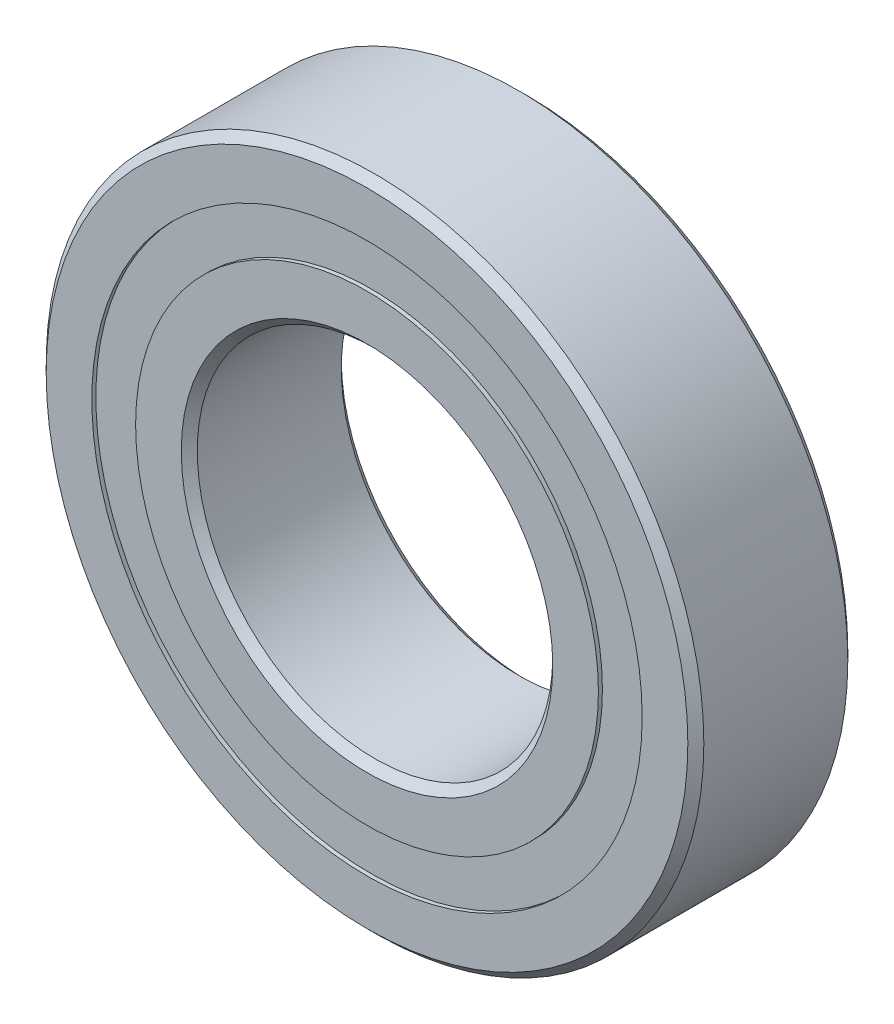
from build123d import *

# Parameters (mm, degrees)
CIRPATTERN1_COUNT = 12
SKETCH5_W         = 1.926640381
SKETCH5_H         = 2.461538462


with BuildPart() as part:
    # Sketch1 → Revolve1 (revolve)
    with BuildSketch(Plane(origin=(0, 0, 0), x_dir=(0, 0, -1), z_dir=(1, 0, 0))):
        with BuildLine():
            Line((4.05, 18.5), (-4.05, 18.5))
            Line((-4.05, 18.5), (-4.5, 18.05))
            Line((-4.5, 18.05), (-4.5, 15.480769231))
            Line((-4.5, 15.480769231), (-2, 15.480769231))
            ThreePointArc((-2, 15.480769231), (0, 16.598359619), (2, 15.480769231))
            Line((2, 15.480769231), (4.5, 15.480769231))
            Line((4.5, 15.480769231), (4.5, 18.05))
            Line((4.5, 18.05), (4.05, 18.5))
        make_face()
    revolve(axis=Axis((0, 0, 4.5), (0, 0, -1)))


with BuildPart() as body_2:
    # Sketch3 → Revolve3 (revolve)
    with BuildSketch(Plane(origin=(0, 0, 0), x_dir=(0, 0, -1), z_dir=(1, 0, 0))):
        with BuildLine():
            Line((-4.5, 13.019230769), (-2, 13.019230769))
            ThreePointArc((-2, 13.019230769), (0, 11.901640381), (2, 13.019230769))
            Line((2, 13.019230769), (4.5, 13.019230769))
            Line((4.5, 13.019230769), (4.5, 10.45))
            Line((4.5, 10.45), (4.05, 10))
            Line((4.05, 10), (-4.05, 10))
            Line((-4.05, 10), (-4.5, 10.45))
            Line((-4.5, 10.45), (-4.5, 13.019230769))
        make_face()
    revolve(axis=Axis((0, 0, 4.5), (0, 0, -1)))


with BuildPart() as body_3:
    # Sketch4 → Revolve4 (revolve)
    with BuildSketch(Plane(origin=(0, 0, 0), x_dir=(0, 0, -1), z_dir=(1, 0, 0))):
        with BuildLine():
            Line((-2.348359619, 14.25), (2.348359619, 14.25))
            ThreePointArc((2.348359619, 14.25), (0, 16.598359619), (-2.348359619, 14.25))
        make_face()
    revolve(axis=Axis((0, 14.25, 2.348359619), (0, 0, -1)))


with BuildPart() as cirpattern1_1:
    # CirPattern1: pattern copy
    add(body_3.part.rotate(Axis((0, 0, -4.5), (0, 0, 1)), 1 * 360 / CIRPATTERN1_COUNT))


with BuildPart() as cirpattern1_2:
    # CirPattern1: pattern copy
    add(body_3.part.rotate(Axis((0, 0, -4.5), (0, 0, 1)), 2 * 360 / CIRPATTERN1_COUNT))


with BuildPart() as cirpattern1_3:
    # CirPattern1: pattern copy
    add(body_3.part.rotate(Axis((0, 0, -4.5), (0, 0, 1)), 3 * 360 / CIRPATTERN1_COUNT))


with BuildPart() as cirpattern1_4:
    # CirPattern1: pattern copy
    add(body_3.part.rotate(Axis((0, 0, -4.5), (0, 0, 1)), 4 * 360 / CIRPATTERN1_COUNT))


with BuildPart() as cirpattern1_5:
    # CirPattern1: pattern copy
    add(body_3.part.rotate(Axis((0, 0, -4.5), (0, 0, 1)), 5 * 360 / CIRPATTERN1_COUNT))


with BuildPart() as cirpattern1_6:
    # CirPattern1: pattern copy
    add(body_3.part.rotate(Axis((0, 0, -4.5), (0, 0, 1)), 6 * 360 / CIRPATTERN1_COUNT))


with BuildPart() as cirpattern1_7:
    # CirPattern1: pattern copy
    add(body_3.part.rotate(Axis((0, 0, -4.5), (0, 0, 1)), 7 * 360 / CIRPATTERN1_COUNT))


with BuildPart() as cirpattern1_8:
    # CirPattern1: pattern copy
    add(body_3.part.rotate(Axis((0, 0, -4.5), (0, 0, 1)), 8 * 360 / CIRPATTERN1_COUNT))


with BuildPart() as cirpattern1_9:
    # CirPattern1: pattern copy
    add(body_3.part.rotate(Axis((0, 0, -4.5), (0, 0, 1)), 9 * 360 / CIRPATTERN1_COUNT))


with BuildPart() as cirpattern1_10:
    # CirPattern1: pattern copy
    add(body_3.part.rotate(Axis((0, 0, -4.5), (0, 0, 1)), 10 * 360 / CIRPATTERN1_COUNT))


with BuildPart() as cirpattern1_11:
    # CirPattern1: pattern copy
    add(body_3.part.rotate(Axis((0, 0, -4.5), (0, 0, 1)), 11 * 360 / CIRPATTERN1_COUNT))


with BuildPart() as body_15:
    # Sketch5 → Revolve5 (revolve)
    with BuildSketch(Plane(origin=(0, 0, 0), x_dir=(0, 0, -1), z_dir=(1, 0, 0))):
        with Locations((-3.31167981, 14.25)):
            Rectangle(SKETCH5_W, SKETCH5_H)
        with Locations((3.31167981, 14.25)):
            Rectangle(SKETCH5_W, SKETCH5_H)
    revolve(axis=Axis((0, 0, 4.5), (0, 0, -1)))


solid = Compound([part.part, body_2.part, body_3.part, cirpattern1_1.part, cirpattern1_2.part, cirpattern1_3.part, cirpattern1_4.part, cirpattern1_5.part, cirpattern1_6.part, cirpattern1_7.part, cirpattern1_8.part, cirpattern1_9.part, cirpattern1_10.part, cirpattern1_11.part, body_15.part])
